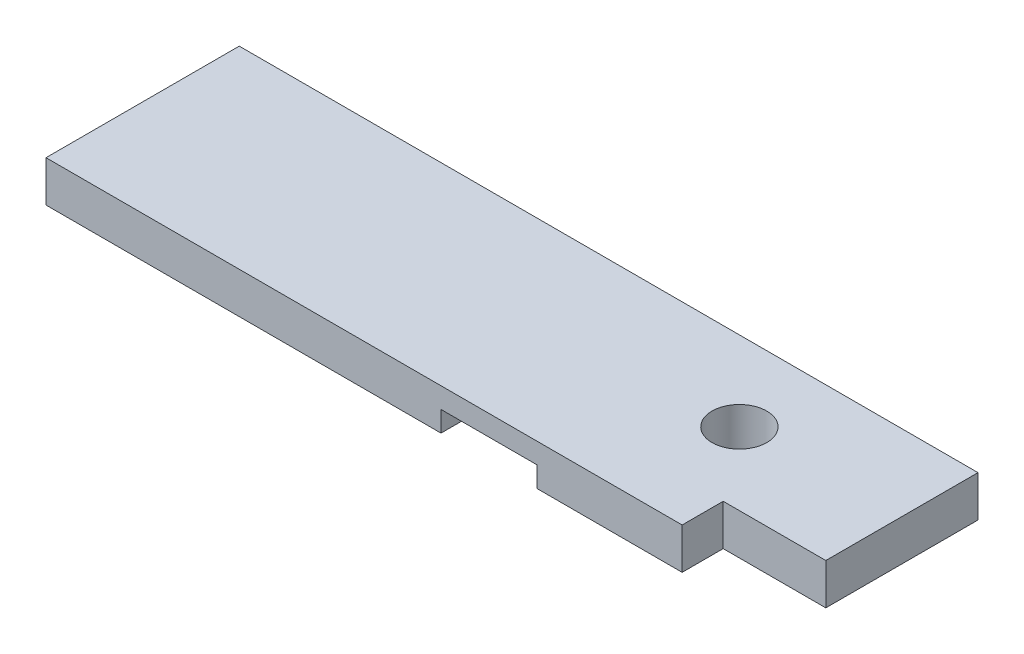
from build123d import *

# Parameters (mm, degrees)
SKETCH1_R           = 25.4
BOSS_EXTRUDE1_DEPTH = 38.1
SKETCH2_W           = 88.9
SKETCH2_H           = 179.4002
CUT_EXTRUDE1_DEPTH  = 19.05


with BuildPart() as part:
    # Sketch1 → Boss-Extrude1 (new body)
    with BuildSketch(Plane(origin=(0, 0, 0), x_dir=(1, 0, 0), z_dir=(0, 1, 0))):
        Polygon((685.8127, 0), (0, 0), (0, -179.4002), (590.5627, -179.4002), (590.5627, -141.2875), (685.8127, -141.2875), align=None)
        with Locations((538.226, -73.918191)):
            Circle(SKETCH1_R, mode=Mode.SUBTRACT)
    extrude(amount=BOSS_EXTRUDE1_DEPTH)

    # Sketch2 → Cut-Extrude1 (cut)
    with BuildSketch(Plane.XZ):
        with Locations((411.15104079, 89.7001)):
            Rectangle(SKETCH2_W, SKETCH2_H)
    extrude(amount=-CUT_EXTRUDE1_DEPTH, mode=Mode.SUBTRACT)


solid = part.part
